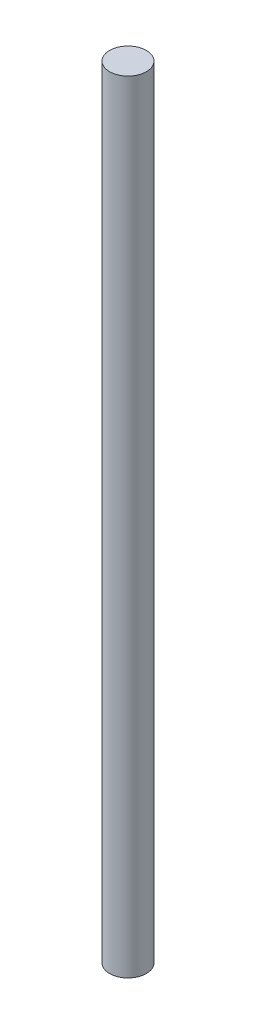
from build123d import *

# Parameters (mm, degrees)
SKETCH_1_R      = 0.75
EXTRUDE_1_DEPTH = 15.9


with BuildPart() as part:
    # 草图1 → 凸台-拉伸1 (new body, symmetric)
    with BuildSketch(Plane(origin=(0, 0, 0), x_dir=(1, 0, 0), z_dir=(0, 1, 0))):
        Circle(SKETCH_1_R)
    extrude(amount=EXTRUDE_1_DEPTH, both=True)


solid = part.part
